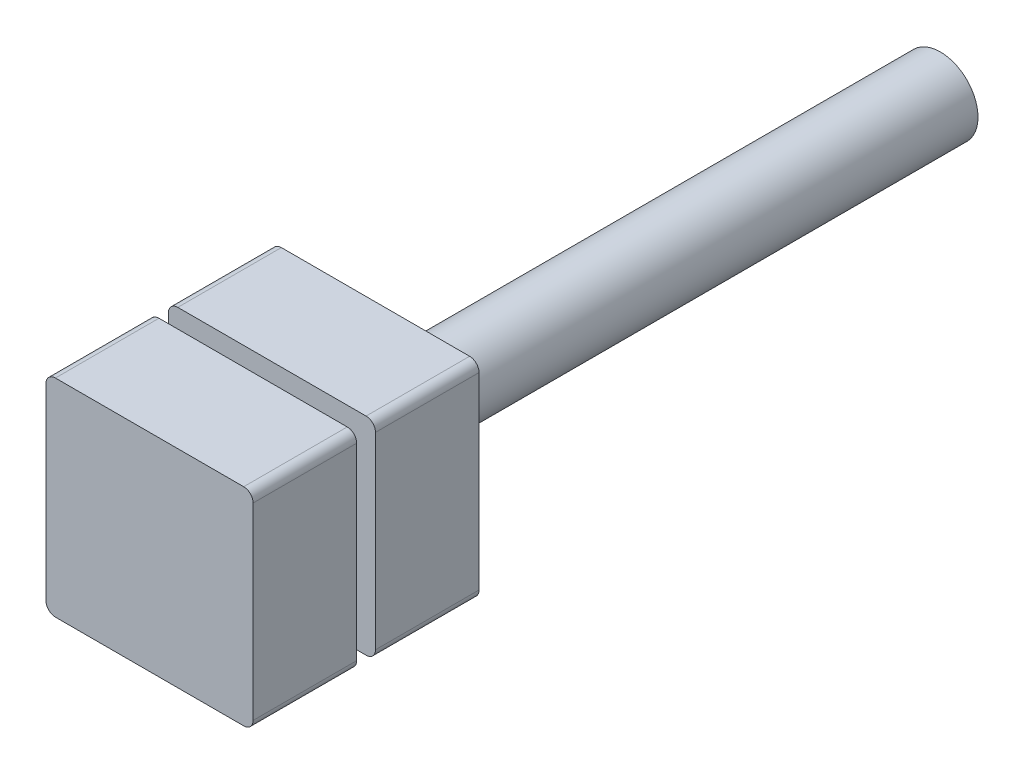
from build123d import *

# Parameters (mm, degrees)
SKETCH1_W           = 22
SKETCH1_H           = 22
BOSS_EXTRUDE1_DEPTH = 24
SKETCH2_W           = 2
SKETCH2_H           = 22
CUT_EXTRUDE1_DEPTH  = 3
CIRPATTERN1_COUNT   = 4
FILLET1_R           = 1
SKETCH3_R           = 4
BOSS_EXTRUDE2_DEPTH = 60


with BuildPart() as part:
    # Sketch1 → Boss-Extrude1 (new body)
    with BuildSketch(Plane.XY):
        Rectangle(SKETCH1_W, SKETCH1_H)
    extrude(amount=BOSS_EXTRUDE1_DEPTH)

    # Sketch2 → Cut-Extrude1 (cut)
    with BuildSketch(Plane(origin=(11, 0, 0), x_dir=(0, 0, -1), z_dir=(1, 0, 0))):
        with Locations((-12, 0)):
            Rectangle(SKETCH2_W, SKETCH2_H)
    cut_extrude1 = extrude(amount=-CUT_EXTRUDE1_DEPTH, mode=Mode.SUBTRACT)

    # CirPattern1: Cut-Extrude1 ×4 about axis
    cirpattern1_axis = Axis((0, 0, 0), (0, 0, 1))
    for i in range(1, CIRPATTERN1_COUNT):
        add(cut_extrude1.rotate(cirpattern1_axis, i * 360 / CIRPATTERN1_COUNT), mode=Mode.SUBTRACT)

    # Fillet1
    fillet1_edges = [part.edges().sort_by_distance(p)[0] for p in [
        (11, -11, 5.5),
        (11, 11, 5.5),
        (-11, -11, 5.5),
        (-11, 11, 5.5),
        (11, -11, 18.5),
        (-11, -11, 18.5),
        (-11, 11, 18.5),
        (11, 11, 18.5),
    ]]
    fillet(fillet1_edges, radius=FILLET1_R)

    # Sketch3 → Boss-Extrude2 (add)
    with BuildSketch(Plane.XY):
        Circle(SKETCH3_R)
    extrude(amount=-BOSS_EXTRUDE2_DEPTH)


solid = part.part
